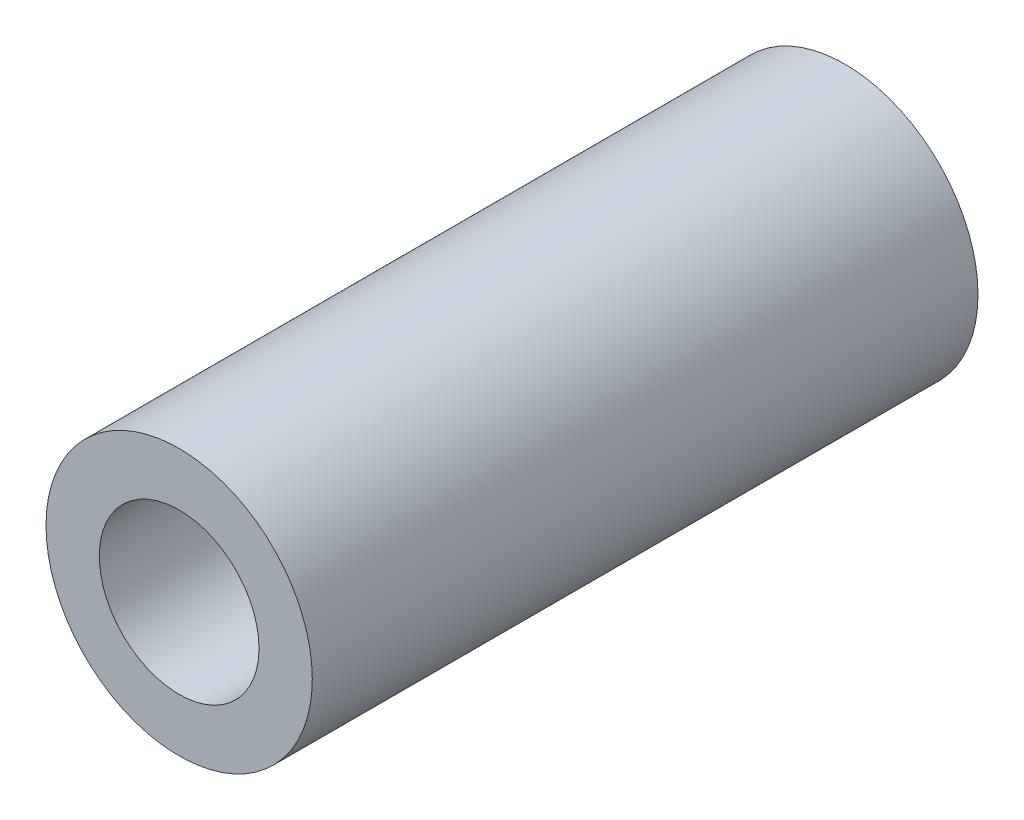
from build123d import *

# Parameters (mm, degrees)
SKETCH1_R           = 5
SKETCH1_R_2         = 3
BOSS_EXTRUDE1_DEPTH = 25


with BuildPart() as part:
    # Sketch1 → Boss-Extrude1 (new body)
    with BuildSketch(Plane.XY):
        Circle(SKETCH1_R)
        Circle(SKETCH1_R_2, mode=Mode.SUBTRACT)
    extrude(amount=BOSS_EXTRUDE1_DEPTH)


solid = part.part
